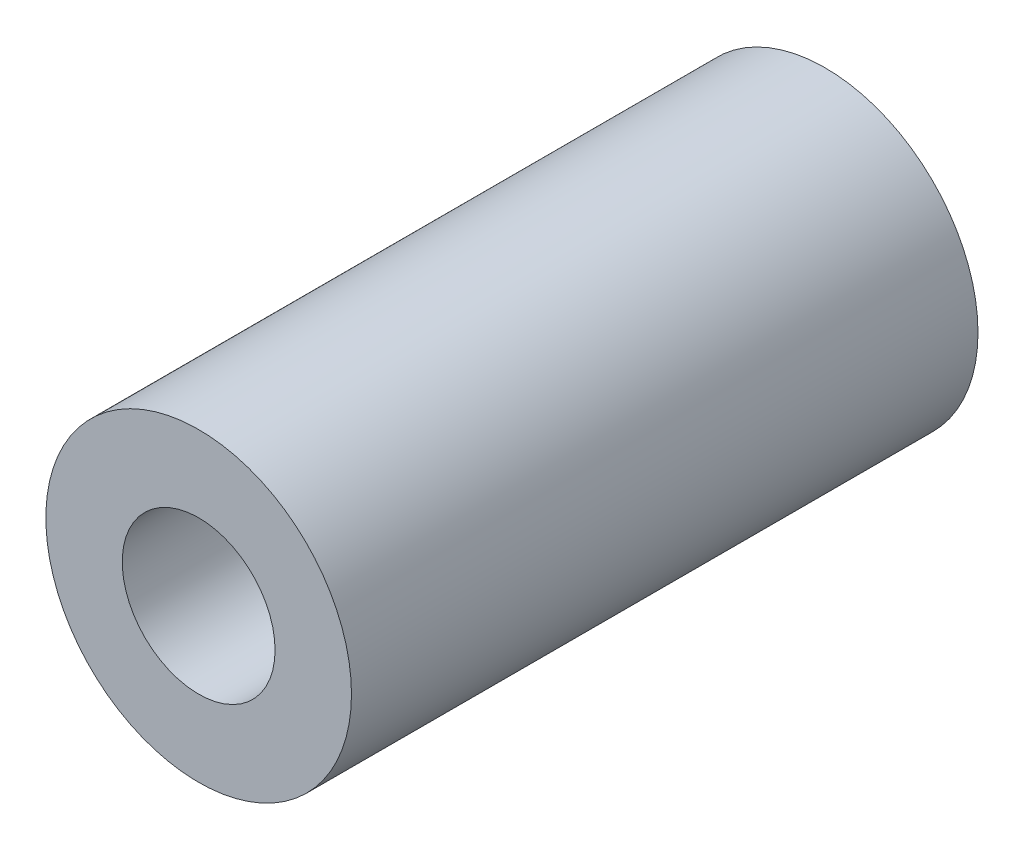
from build123d import *

# Parameters (mm, degrees)
SKETCH_1_R      = 10
SKETCH_1_R_2    = 5
EXTRUDE_1_DEPTH = 41


with BuildPart() as part:
    # 草图1 → 凸台-拉伸1 (new body)
    with BuildSketch(Plane.XY):
        Circle(SKETCH_1_R)
        Circle(SKETCH_1_R_2, mode=Mode.SUBTRACT)
    extrude(amount=EXTRUDE_1_DEPTH)


solid = part.part
